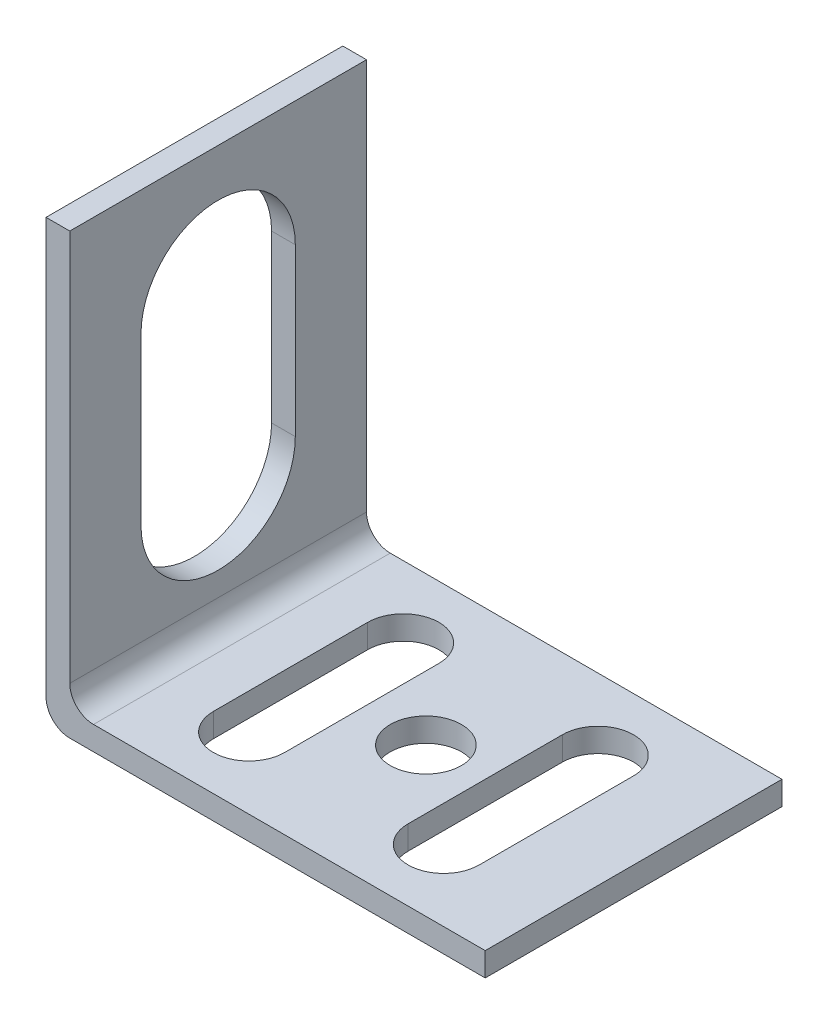
from build123d import *

# Parameters (mm, degrees)
BOSS_EXTRUDE1_DEPTH = 25
CUT_EXTRUDE1_DEPTH  = 25
SKETCH3_R           = 3
CUT_EXTRUDE2_DEPTH  = 25


with BuildPart() as part:
    # Sketch1 → Boss-Extrude1 (new body)
    with BuildSketch(Plane.XY):
        with BuildLine():
            Line((-19.099339108, 23.459186619), (-19.099339108, -11.540813381))
            ThreePointArc((-19.099339108, -11.540813381), (-18.51355267, -12.955026943), (-17.099339108, -13.540813381))
            Line((-17.099339108, -13.540813381), (17.900660892, -13.540813381))
            Line((17.900660892, -13.540813381), (17.900660892, -11.540813381))
            Line((17.900660892, -11.540813381), (-15.099339108, -11.540813381))
            ThreePointArc((-15.099339108, -11.540813381), (-16.51355267, -10.955026943), (-17.099339108, -9.540813381))
            Line((-17.099339108, -9.540813381), (-17.099339108, 23.459186619))
            Line((-17.099339108, 23.459186619), (-19.099339108, 23.459186619))
        make_face()
    extrude(amount=BOSS_EXTRUDE1_DEPTH)

    # Sketch2 → Cut-Extrude1 (cut)
    with BuildSketch(Plane.ZY.offset(19.099339108)):
        with BuildLine():
            Line((6, -1.040813381), (6, 12.959186619))
            ThreePointArc((6, 12.959186619), (12.5, 19.459186619), (19, 12.959186619))
            Line((19, 12.959186619), (19, -1.040813381))
            ThreePointArc((19, -1.040813381), (12.5, -7.540813381), (6, -1.040813381))
        make_face()
    extrude(amount=-CUT_EXTRUDE1_DEPTH, mode=Mode.SUBTRACT)

    # Sketch3 → Cut-Extrude2 (cut)
    with BuildSketch(Plane.XZ.offset(13.540813381)):
        with Locations((0.400660892, 12.5)):
            Circle(SKETCH3_R)
        with BuildLine():
            Line((5.400660892, 6), (5.400660892, 19))
            ThreePointArc((5.400660892, 19), (8.400660892, 22), (11.400660892, 19))
            Line((11.400660892, 19), (11.400660892, 6))
            ThreePointArc((11.400660892, 6), (8.400660892, 3), (5.400660892, 6))
        make_face()
        with BuildLine():
            Line((-11.002045654, 6), (-11.002045654, 19))
            ThreePointArc((-11.002045654, 19), (-8.002045654, 22), (-5.002045654, 19))
            Line((-5.002045654, 19), (-5.002045654, 6))
            ThreePointArc((-5.002045654, 6), (-8.002045654, 3), (-11.002045654, 6))
        make_face()
    extrude(amount=-CUT_EXTRUDE2_DEPTH, mode=Mode.SUBTRACT)


solid = part.part
